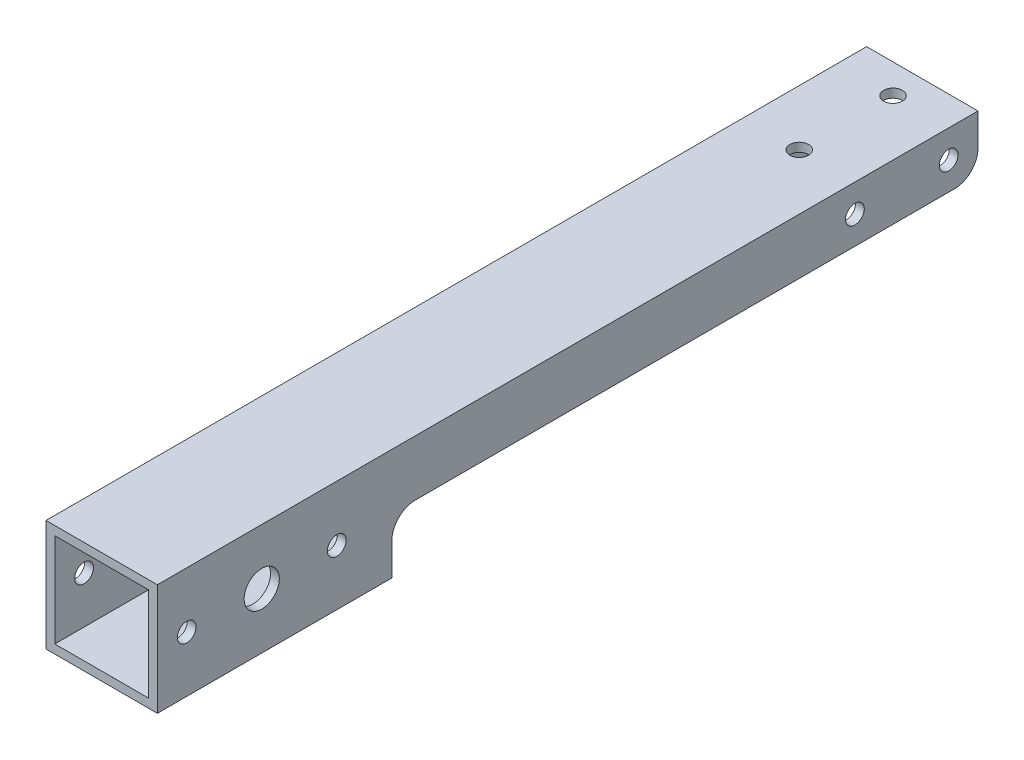
from build123d import *

# Parameters (mm, degrees)
ESBO_O1_W                = 19
ESBO_O1_H                = 19
ESBO_O1_W_2              = 16
ESBO_O1_H_2              = 16
RESSALTO_EXTRUS_O1_DEPTH = 140
ESBO_O2_R                = 1.6
ESBO_O2_R_2              = 3
CORTE_EXTRUS_O1_DEPTH    = 20
ESBO_O3_R                = 1.6
CORTE_EXTRUS_O2_DEPTH    = 1.5
ESBO_O5_W                = 19
ESBO_O5_H                = 9.5
CORTE_EXTRUS_O4_DEPTH    = 100
FILETE1_R                = 4


with BuildPart() as part:
    # Esboço1 → Ressalto-extrusão1 (new body)
    with BuildSketch(Plane.XY):
        Rectangle(ESBO_O1_W, ESBO_O1_H)
        Rectangle(ESBO_O1_W_2, ESBO_O1_H_2, mode=Mode.SUBTRACT)
    extrude(amount=RESSALTO_EXTRUS_O1_DEPTH)

    # Esboço2 → Corte-extrusão1 (cut, through all)
    with BuildSketch(Plane(origin=(9.5, 0, 0), x_dir=(0, 0, -1), z_dir=(1, 0, 0))):
        with Locations((-109.38750305, 0)):
            Circle(ESBO_O2_R)
        with Locations((-135, 0)):
            Circle(ESBO_O2_R)
        with Locations((-122.193751525, 0)):
            Circle(ESBO_O2_R_2)
        with Locations((-5, 4.75)):
            Circle(ESBO_O2_R)
        with Locations((-21, 4.75)):
            Circle(ESBO_O2_R)
    extrude(amount=-CORTE_EXTRUS_O1_DEPTH, mode=Mode.SUBTRACT)

    # Esboço3 → Corte-extrusão2 (cut)
    with BuildSketch(Plane(origin=(0, 9.5, 0), x_dir=(1, 0, 0), z_dir=(0, 1, 0))):
        with Locations((0, -21)):
            Circle(ESBO_O3_R)
        with Locations((0, -5)):
            Circle(ESBO_O3_R)
    extrude(amount=-CORTE_EXTRUS_O2_DEPTH, mode=Mode.SUBTRACT)

    # Esboço5 → Corte-extrusão4 (cut)
    with BuildSketch(Plane(origin=(0, 0, 0), x_dir=(-1, 0, 0), z_dir=(0, 0, -1))):
        with Locations((0, -4.75)):
            Rectangle(ESBO_O5_W, ESBO_O5_H)
    extrude(amount=-CORTE_EXTRUS_O4_DEPTH, mode=Mode.SUBTRACT)

    # Filete1
    filete1_edges = [part.edges().sort_by_distance(p)[0] for p in [
        (-8.75, 0, 0),
        (8.75, 0, 0),
        (-8.75, 0, 100),
        (8.75, 0, 100),
    ]]
    fillet(filete1_edges, radius=FILETE1_R)


solid = part.part
